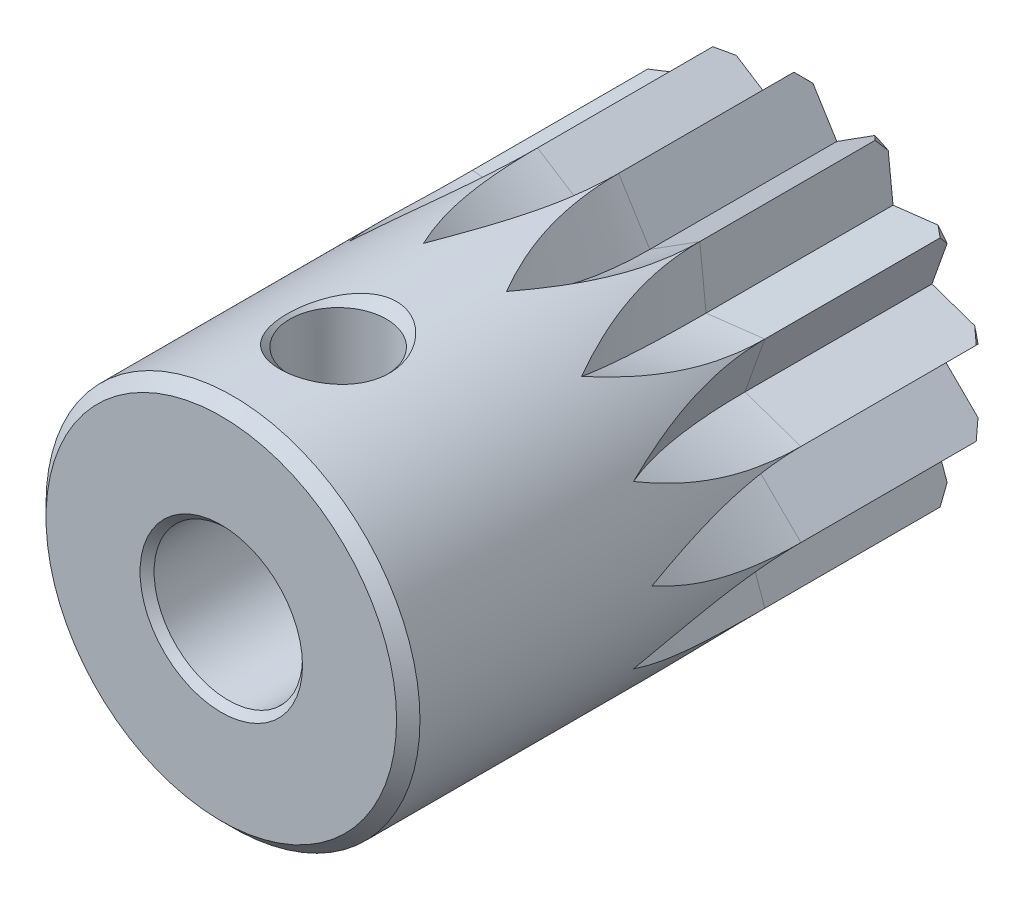
from build123d import *

# Parameters (mm, degrees)
SKETCH2_R          = 16
CUT_EXTRUDE1_DEPTH = 8


with BuildPart() as part:
    # Sketch1 → Revolve1 (revolve)
    with BuildSketch(Plane(origin=(0, 0, 0), x_dir=(0, 0, -1), z_dir=(1, 0, 0)), mode=Mode.PRIVATE) as revolve1_sk:
        Polygon((-25, 3.4749999999999996), (-24.7, 3.175), (-0.3, 3.175), (0, 3.4749999999999996), (0, 7.5), (-0.5, 8), (-24.5, 8), (-25, 7.5), align=None)
    revolve(revolve1_sk.sketch.rotate(Axis((0, 0, 0), (0, 0, 1)), 270), axis=Axis((0, 0, 0), (0, 0, 1)))

    # Sketch2 → Cut-Extrude1 (cut)
    with BuildSketch(Plane.XY.offset(8)):
        Circle(SKETCH2_R)
        Polygon((-7.7994232974546, 1.7801674716505), (-6, -2.66e-15), (-7.7994232974546, -1.7801674716505), (-5.4058132074145, -2.6033024347054003), (-6.2546518597442, -4.9879184148699), (-3.7409388111524002, -4.6909888948082), (-3.4710699129405, -7.2077509432194), (-1.3351256037378998, -5.8495674730909), (7.11e-15, -8), (1.3351256037378998, -5.8495674730909), (3.4710699129405, -7.2077509432193), (3.7409388111524002, -4.6909888948082), (6.2546518597442, -4.9879184148699), (5.4058132074145, -2.6033024347053), (7.7994232974546, -1.7801674716505), (6, 7.99e-15), (7.7994232974546, 1.7801674716505), (5.4058132074145, 2.6033024347054003), (6.2546518597442, 4.9879184148699), (3.7409388111524002, 4.6909888948082), (3.4710699129405, 7.2077509432194), (1.3351256037378998, 5.8495674730909), (-7.77e-15, 8), (-1.3351256037378998, 5.8495674730909), (-3.4710699129405, 7.2077509432194), (-3.7409388111524002, 4.6909888948082), (-6.2546518597442, 4.9879184148699), (-5.4058132074145, 2.6033024347053), align=None, mode=Mode.SUBTRACT)
    extrude(amount=-CUT_EXTRUDE1_DEPTH, mode=Mode.SUBTRACT)

    # Sketch3 → Cut-Revolve1 (revolve, cut)
    with BuildSketch(Plane.XY.offset(8)):
        Polygon((-2.2252093395631, 17.749279121818), (0, 8), (-1.3351256037378998, 5.8495674730909), (-3.4710699129405, 7.2077509432194), (-5.6962792525036, 16.957030065038), align=None)
    revolve(axis=Axis((-5.6962792525036, 16.957030065038, 8), (0.9749279121818636, 0.22252093395613937, 0)), mode=Mode.SUBTRACT)

    # Sketch4 → Cut-Revolve2 (revolve, cut)
    with BuildSketch(Plane.XY.offset(8)):
        Polygon((5.6962792525035795, 16.95703006503738), (3.4710699129404805, 7.207750943219364), (1.3351256037378663, 5.8495674730909215), (-4.3e-16, 8.000000000000073), (2.2252093395633574, 17.74927912181863), align=None)
    revolve(axis=Axis((2.2252093395633574, 17.74927912181863, 8), (0.9749279121817834, -0.22252093395649067, 0)), mode=Mode.SUBTRACT)

    # Sketch5 → Cut-Revolve3 (revolve, cut)
    with BuildSketch(Plane.XY.offset(8)):
        Polygon((12.489549878331436, 12.806233239549918), (6.254651859744247, 4.987918414869839), (3.7409388111523727, 4.69098889480814), (3.4710699129405, 7.2077509432193825), (9.705967931528159, 15.026065767899839), align=None)
    revolve(axis=Axis((9.705967931528159, 15.026065767899839, 8), (0.7818314824679159, -0.6234898018588765, 0)), mode=Mode.SUBTRACT)

    # Sketch6 → Cut-Revolve4 (revolve, cut)
    with BuildSketch(Plane.XY.offset(8)):
        Polygon((16.809111976478512, 6.119004862825916), (7.799423297454563, 1.780167471650481), (5.405813207414458, 2.603302434705323), (6.254651859744269, 4.98791841486987), (15.2643405387688, 9.326755806045437), align=None)
    revolve(axis=Axis((15.2643405387688, 9.326755806045437, 8), (0.43388373911739375, -0.9009688679024983, 0)), mode=Mode.SUBTRACT)

    # Sketch7 → Cut-Revolve5 (revolve, cut)
    with BuildSketch(Plane.XY.offset(8)):
        Polygon((17.799423297454304, -1.7801674716506055), (7.799423297454564, -1.780167471650553), (5.999999999999952, -8.02e-15), (7.79942329745464, 1.7801674716504932), (17.79942329745496, 1.7801674716503062), align=None)
    revolve(axis=Axis((17.79942329745496, 1.7801674716503062, 8), (-1.8515e-13, -1, 0)), mode=Mode.SUBTRACT)

    # Sketch8 → Cut-Revolve6 (revolve, cut)
    with BuildSketch(Plane.XY.offset(8)):
        Polygon((15.264340538768215, -9.326755806045275), (6.254651859744242, -4.987918414869841), (5.4058132074144885, -2.603302434705292), (7.799423297454639, -1.7801674716504925), (16.80911197647908, -6.1190048628263005), align=None)
    revolve(axis=Axis((16.80911197647908, -6.1190048628263005, 8), (-0.43388373911771694, -0.9009688679023427, 0)), mode=Mode.SUBTRACT)

    # Sketch9 → Cut-Revolve7 (revolve, cut)
    with BuildSketch(Plane.XY.offset(8)):
        Polygon((9.705967931527697, -15.026065767899471), (3.4710699129404814, -7.207750943219363), (3.7409388111524087, -4.690988894808141), (6.254651859744309, -4.987918414869898), (12.489549878331783, -12.806233239550549), align=None)
    revolve(axis=Axis((12.489549878331783, -12.806233239550549, 8), (-0.7818314824681412, -0.623489801858594, 0)), mode=Mode.SUBTRACT)

    # Sketch10 → Cut-Revolve8 (revolve, cut)
    with BuildSketch(Plane.XY.offset(8)):
        Polygon((2.225209339563098, -17.749279121818), (-4.4e-16, -8), (1.3351256037378996, -5.8495674730909), (3.4710699129404996, -7.2077509432194), (5.696279252503599, -16.957030065038), align=None)
    revolve(axis=Axis((5.696279252503599, -16.957030065038, 8), (-0.9749279121818636, -0.22252093395613928, 0)), mode=Mode.SUBTRACT)

    # Sketch11 → Cut-Revolve9 (revolve, cut)
    with BuildSketch(Plane.XY.offset(8)):
        Polygon((-5.696279252503582, -16.957030065037376), (-3.471069912940484, -7.20775094321936), (-1.3351256037378698, -5.849567473090918), (-3.04e-15, -8.00000000000007), (-2.225209339563361, -17.749279121818628), align=None)
    revolve(axis=Axis((-2.225209339563361, -17.749279121818628, 8), (-0.9749279121817834, 0.22252093395649067, 0)), mode=Mode.SUBTRACT)

    # Sketch12 → Cut-Revolve10 (revolve, cut)
    with BuildSketch(Plane.XY.offset(8)):
        Polygon((-12.489549878331427, -12.806233239549925), (-6.254651859744238, -4.987918414869844), (-3.7409388111523643, -4.690988894808146), (-3.471069912940491, -7.207750943219389), (-9.705967931528152, -15.026065767899846), align=None)
    revolve(axis=Axis((-9.705967931528152, -15.026065767899846, 8), (-0.7818314824679159, 0.6234898018588765, 0)), mode=Mode.SUBTRACT)

    # Sketch13 → Cut-Revolve11 (revolve, cut)
    with BuildSketch(Plane.XY.offset(8)):
        Polygon((-16.80911197647851, -6.119004862825915), (-7.7994232974545605, -1.78016747165048), (-5.405813207414456, -2.603302434705322), (-6.254651859744266, -4.987918414869869), (-15.264340538768797, -9.326755806045437), align=None)
    revolve(axis=Axis((-15.264340538768797, -9.326755806045437, 8), (-0.43388373911739325, 0.9009688679024985, 0)), mode=Mode.SUBTRACT)

    # Sketch14 → Cut-Revolve12 (revolve, cut)
    with BuildSketch(Plane.XY.offset(8)):
        Polygon((-17.799423297454275, 1.7801674716504374), (-7.7994232974545605, 1.7801674716504818), (-5.999999999999936, -4.142e-14), (-7.799423297454601, -1.7801674716505562), (-17.799423297454904, -1.780167471650467), align=None)
    revolve(axis=Axis((-17.799423297454904, -1.780167471650467, 8), (1.7638e-13, 1, 0)), mode=Mode.SUBTRACT)

    # Sketch15 → Cut-Revolve13 (revolve, cut)
    with BuildSketch(Plane.XY.offset(8)):
        Polygon((-15.264340538768213, 9.326755806045275), (-6.25465185974424, 4.98791841486984), (-5.405813207414487, 2.6033024347052915), (-7.799423297454637, 1.7801674716504916), (-16.80911197647908, 6.1190048628263), align=None)
    revolve(axis=Axis((-16.80911197647908, 6.1190048628263, 8), (0.43388373911771727, 0.9009688679023425, 0)), mode=Mode.SUBTRACT)

    # Sketch16 → Cut-Revolve14 (revolve, cut)
    with BuildSketch(Plane.XY.offset(8)):
        Polygon((-9.705967931527695, 15.02606576789947), (-3.4710699129404805, 7.20775094321936), (-3.740938811152408, 4.690988894808139), (-6.254651859744307, 4.987918414869895), (-12.48954987833178, 12.806233239550547), align=None)
    revolve(axis=Axis((-12.48954987833178, 12.806233239550547, 8), (0.7818314824681409, 0.6234898018585943, 0)), mode=Mode.SUBTRACT)

    # Sketch17 → Cut-Revolve15 (revolve, cut)
    with BuildSketch(Plane.XY.offset(20), mode=Mode.PRIVATE) as cut_revolve15_sk:
        Polygon((0, 0), (-2.0669999999999997, 8.9e-16), (-2.0669999999999997, 7.567), (-2.5, 8), (-2.5, 9), (5.5e-16, 9), align=None)
    revolve(cut_revolve15_sk.sketch.rotate(Axis((5.5e-16, 9, 20), (-6e-17, -1, 0)), 45.957284951), axis=Axis((5.5e-16, 9, 20), (-6e-17, -1, 0)), mode=Mode.SUBTRACT)


solid = part.part
